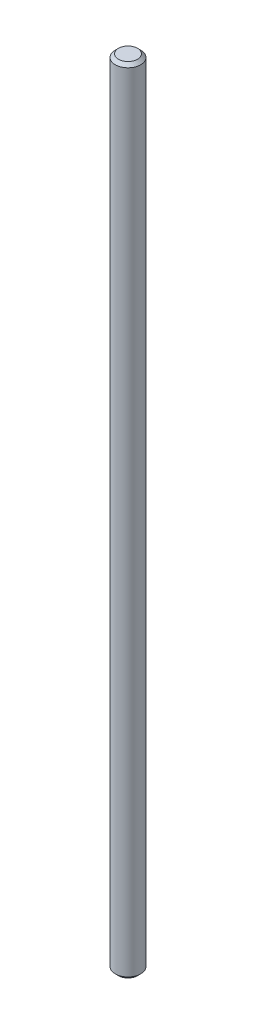
from build123d import *

# Parameters (mm, degrees)
SKETCH_1_R      = 4
EXTRUDE_1_DEPTH = 250
CHAMFER_1_SIZE  = 1


with BuildPart() as part:
    # 草图1 → 凸台-拉伸1 (new body)
    with BuildSketch(Plane(origin=(0, 0, 0), x_dir=(1, 0, 0), z_dir=(0, 1, 0))):
        Circle(SKETCH_1_R)
    extrude(amount=EXTRUDE_1_DEPTH)

    # 倒角1
    chamfer_1_edges = [part.edges().sort_by_distance(p)[0] for p in [
        (-4, 0, 0),
        (-4, 250, 0),
    ]]
    chamfer(chamfer_1_edges, length=CHAMFER_1_SIZE)


solid = part.part
